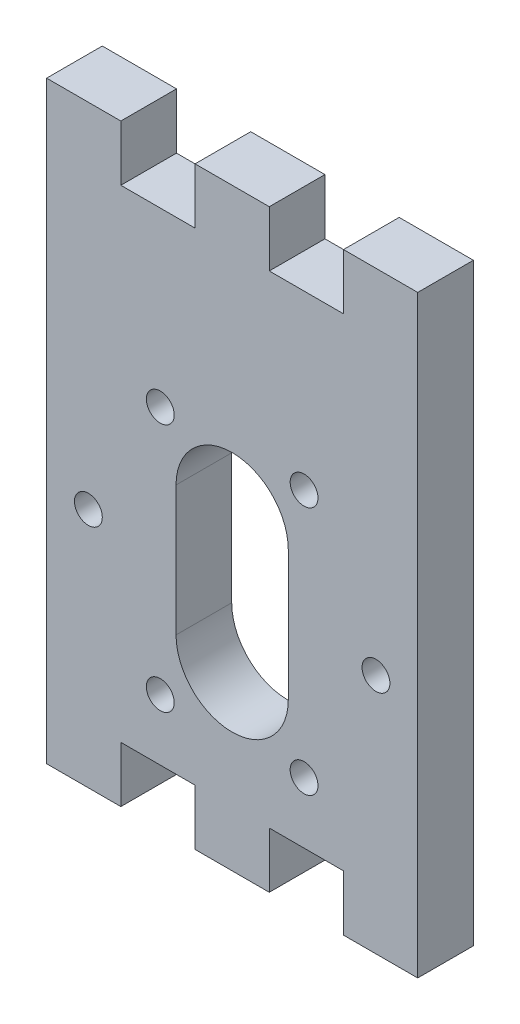
from build123d import *

# Parameters (mm, degrees)
ESQUISSE1_R        = 1.5
BOSS_EXTRU_1_DEPTH = 6


with BuildPart() as part:
    # Esquisse1 → Boss.-Extru.1 (new body)
    with BuildSketch(Plane.XY):
        Polygon((-20, 58), (-12, 58), (-12, 52), (-4, 52), (-4, 58), (4, 58), (4, 52), (12, 52), (12, 58), (20, 58), (20, -1), (20, -6), (12, -6), (12, 0), (4, 0), (4, -6), (-4, -6), (-4, 0), (-12, 0), (-12, -6), (-20, -6), align=None)
        with Locations((-15.5, 20)):
            Circle(ESQUISSE1_R, mode=Mode.SUBTRACT)
        with Locations((-7.75, 33.423393759)):
            Circle(ESQUISSE1_R, mode=Mode.SUBTRACT)
        with Locations((7.75, 33.423393759)):
            Circle(ESQUISSE1_R, mode=Mode.SUBTRACT)
        with Locations((15.5, 20)):
            Circle(ESQUISSE1_R, mode=Mode.SUBTRACT)
        with Locations((7.75, 6.576606241)):
            Circle(ESQUISSE1_R, mode=Mode.SUBTRACT)
        with Locations((-7.75, 6.576606241)):
            Circle(ESQUISSE1_R, mode=Mode.SUBTRACT)
        with BuildLine():
            Line((-6.05, 27), (-6.05, 13))
            ThreePointArc((-6.05, 13), (0, 6.95), (6.05, 13))
            Line((6.05, 13), (6.05, 27))
            ThreePointArc((6.05, 27), (0, 33.05), (-6.05, 27))
        make_face(mode=Mode.SUBTRACT)
    extrude(amount=BOSS_EXTRU_1_DEPTH)


solid = part.part
